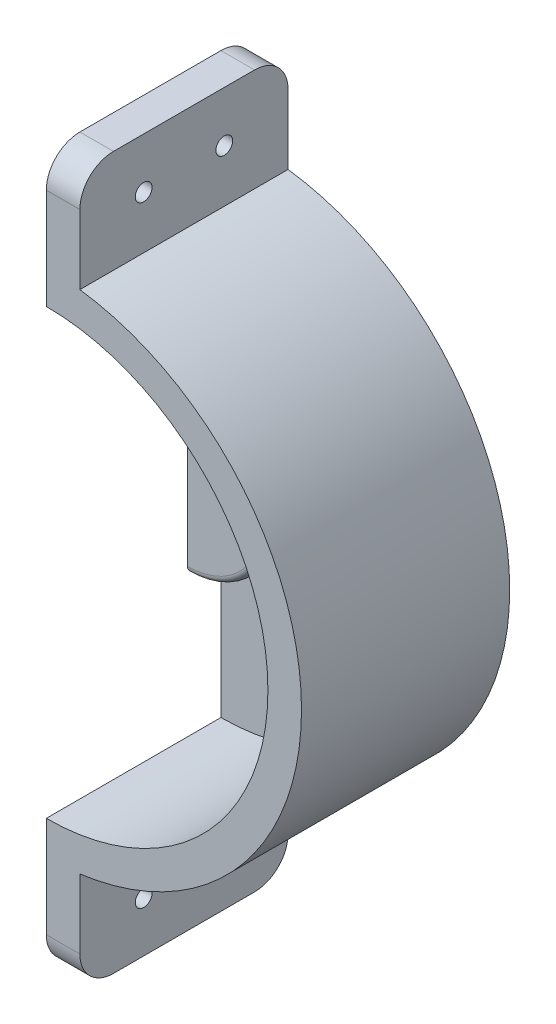
from build123d import *

# Parameters (mm, degrees)
SALIENTE_EXTRUIR1_DEPTH = 5
SALIENTE_EXTRUIR2_DEPTH = 26
SALIENTE_EXTRUIR3_DEPTH = 5
REDONDEO1_R             = 1
SALIENTE_EXTRUIR4_DEPTH = 26
REDONDEO2_R             = 5
CROQUIS5_R              = 1.25
CORTAR_EXTRUIR1_DEPTH   = 5


with BuildPart() as part:
    # Croquis1 → Saliente-Extruir1 (new body)
    with BuildSketch(Plane.XY):
        with BuildLine():
            Line((0, -38), (0, 38))
            Line((0, 38), (0, 53))
            Line((0, 53), (5, 53))
            Line((5, 53), (5, 37.669616404))
            ThreePointArc((5, 37.669616404), (38, 0), (5, -37.669616404))
            Line((5, -37.669616404), (5, -53))
            Line((5, -53), (0, -53))
            Line((0, -53), (0, -38))
        make_face()
    extrude(amount=SALIENTE_EXTRUIR1_DEPTH)

    # Croquis2 → Saliente-Extruir2 (add)
    with BuildSketch(Plane.XY.offset(5)):
        with BuildLine():
            Line((0, -38), (0, -33))
            ThreePointArc((0, -33), (33, 0), (0, 33))
            Line((0, 33), (0, 38))
            ThreePointArc((0, 38), (38, 0), (0, -38))
        make_face()
    extrude(amount=SALIENTE_EXTRUIR2_DEPTH)

    # Croquis3 → Saliente-Extruir3 (add)
    with BuildSketch(Plane.XY.offset(5)):
        with BuildLine():
            Line((0, 12), (0, -12))
            ThreePointArc((0, -12), (12, 0), (0, 12))
        make_face()
    extrude(amount=SALIENTE_EXTRUIR3_DEPTH)

    # Redondeo1
    redondeo1_edges = [part.edges().sort_by_distance(p)[0] for p in [
        (12, 0, 10),
    ]]
    fillet(redondeo1_edges, radius=REDONDEO1_R)

    # Croquis4 → Saliente-Extruir4 (add)
    with BuildSketch(Plane.XY.offset(5)):
        with BuildLine():
            Line((0, -38), (0, -53))
            Line((0, -53), (5, -53))
            Line((5, -53), (5, -37.669616404))
            ThreePointArc((5, -37.669616404), (2.505451722, -37.917314141), (0, -38))
        make_face()
        with BuildLine():
            Line((5, 37.669616404), (5, 53))
            Line((5, 53), (0, 53))
            Line((0, 53), (0, 38))
            ThreePointArc((0, 38), (2.505451722, 37.917314141), (5, 37.669616404))
        make_face()
    extrude(amount=SALIENTE_EXTRUIR4_DEPTH)

    # Redondeo2
    redondeo2_edges = [part.edges().sort_by_distance(p)[0] for p in [
        (2.5, 53, 0),
        (2.5, -53, 31),
        (2.5, 53, 31),
        (2.5, -53, 0),
    ]]
    fillet(redondeo2_edges, radius=REDONDEO2_R)

    # Croquis5 → Cortar-Extruir1 (cut)
    with BuildSketch(Plane.ZY):
        with Locations((9.5, 45.5)):
            Circle(CROQUIS5_R)
        with Locations((21.5, 45.5)):
            Circle(CROQUIS5_R)
        with Locations((21.5, -45.5)):
            Circle(CROQUIS5_R)
        with Locations((9.5, -45.5)):
            Circle(CROQUIS5_R)
    extrude(amount=-CORTAR_EXTRUIR1_DEPTH, mode=Mode.SUBTRACT)


solid = part.part
